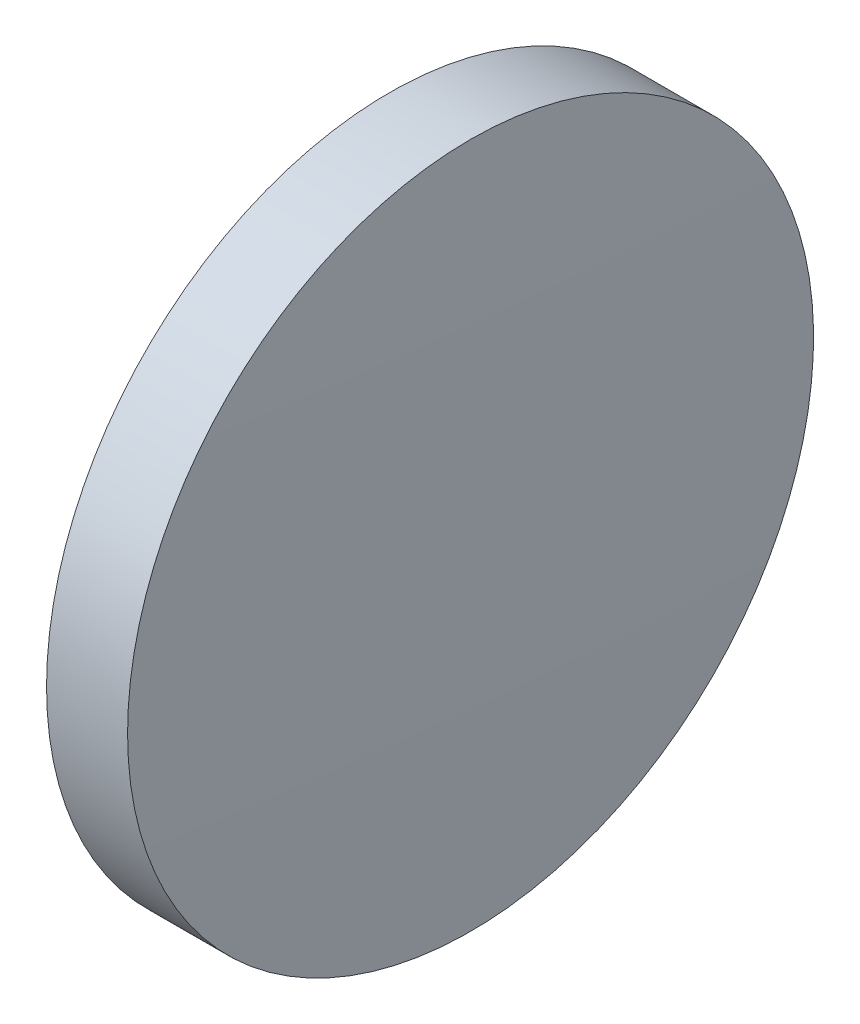
from build123d import *


with BuildPart() as part:
    # 草图1 → 旋转1 (revolve)
    with BuildSketch(Plane.XY):
        with BuildLine():
            Line((115.773606431, 65.233554926), (115.773606431, 77.933554926))
            Line((115.773606431, 77.933554926), (118.773875623, 77.933554926))
            ThreePointArc((118.773875623, 77.933554926), (118.905671626, 71.584162797), (118.949606431, 65.233554926))
            Line((118.949606431, 65.233554926), (115.773606431, 65.233554926))
        make_face()
    revolve(axis=Axis((110.165373228, 65.233554926, 0), (1, 0, 0)))


solid = part.part
